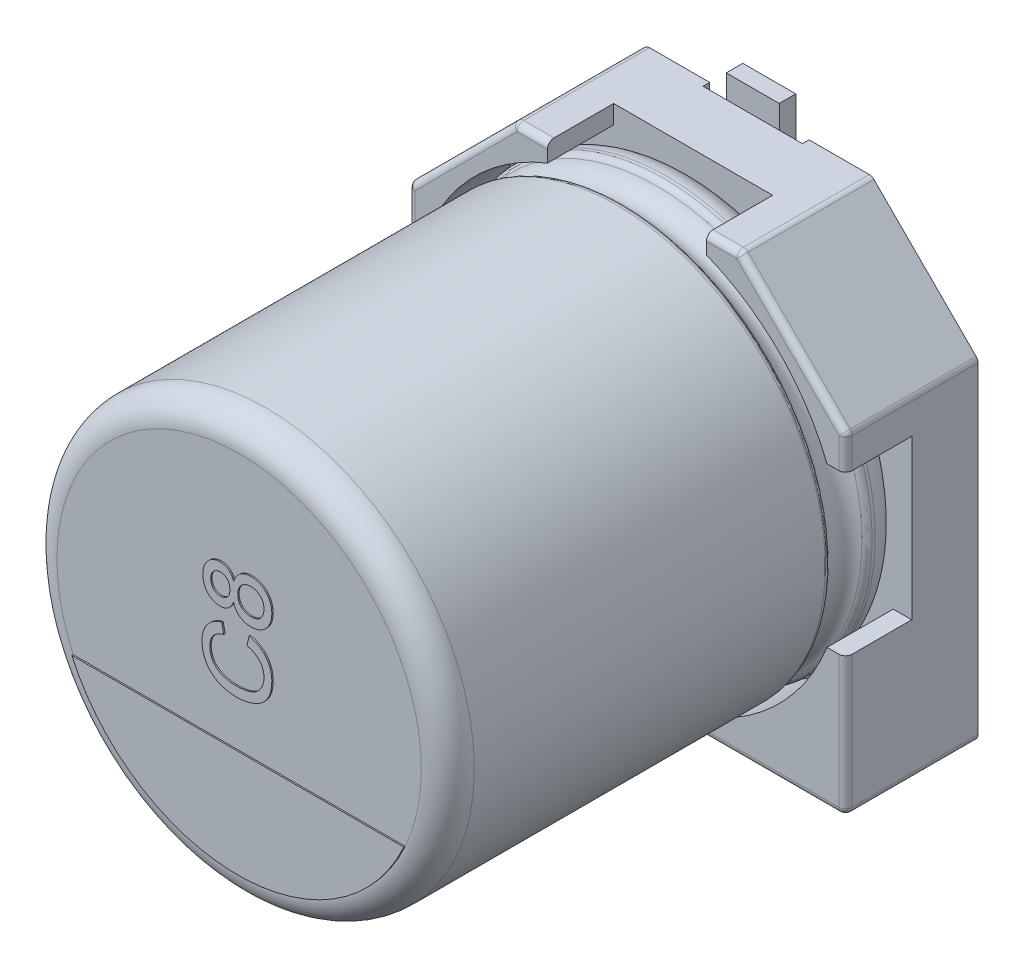
from build123d import *

# Parameters (mm, degrees)
BOSS_EXTRUDE1_DEPTH = 1
BOSS_EXTRUDE2_DEPTH = 1
SKETCH7_R           = 0.35
BOSS_EXTRUDE3_DEPTH = 0.15
SKETCH9_W           = 1.5
SKETCH9_H           = 2.35
CUT_EXTRUDE1_DEPTH  = 0.1
FILLET1_R           = 0.1
FILLET2_R           = 0.1
BOSS_EXTRUDE4_DEPTH = 0.02
TEXT_2_DEPTH        = 0.02
SKETCH19_W          = 0.8
SKETCH19_H          = 2.6
BOSS_EXTRUDE6_DEPTH = 0.25


with BuildPart() as part:
    # Sketch2 → Boss-Extrude1 (new body)
    with BuildSketch(Plane.XY):
        Polygon((-3.3, 1.7), (-1.7, 3.3), (1.7, 3.3), (3.3, 1.7), (3.3, -3.3), (-3.3, -3.3), align=None)
    extrude(amount=BOSS_EXTRUDE1_DEPTH)

    # Sketch4 → Boss-Extrude2 (add)
    with BuildSketch(Plane.XY.offset(1)):
        with BuildLine():
            Line((-3.3, 1.7), (-1.7, 3.3))
            Line((-1.7, 3.3), (-1.2, 3.3))
            Line((-1.2, 3.3), (-1.2, 3.020347662))
            ThreePointArc((-1.2, 3.020347662), (-2.298097039, 2.298097039), (-3.020347662, 1.2))
            Line((-3.020347662, 1.2), (-3.3, 1.2))
            Line((-3.3, 1.2), (-3.3, 1.7))
        make_face()
        with BuildLine():
            Line((1.7, 3.3), (3.3, 1.7))
            Line((3.3, 1.7), (3.3, 1.2))
            Line((3.3, 1.2), (3.020347662, 1.2))
            ThreePointArc((3.020347662, 1.2), (2.298097039, 2.298097039), (1.2, 3.020347662))
            Line((1.2, 3.020347662), (1.2, 3.3))
            Line((1.2, 3.3), (1.7, 3.3))
        make_face()
        with BuildLine():
            Line((3.3, -1.2), (3.3, -3.3))
            Line((3.3, -3.3), (1.2, -3.3))
            Line((1.2, -3.3), (1.2, -3.020347662))
            ThreePointArc((1.2, -3.020347662), (2.298097039, -2.298097039), (3.020347662, -1.2))
            Line((3.020347662, -1.2), (3.3, -1.2))
        make_face()
        with BuildLine():
            Line((-3.3, -1.2), (-3.3, -3.3))
            Line((-3.3, -3.3), (-1.2, -3.3))
            Line((-1.2, -3.3), (-1.2, -3.020347662))
            ThreePointArc((-1.2, -3.020347662), (-2.298097039, -2.298097039), (-3.020347662, -1.2))
            Line((-3.020347662, -1.2), (-3.3, -1.2))
        make_face()
    extrude(amount=BOSS_EXTRUDE2_DEPTH)

    # Sketch7 → Boss-Extrude3 (add)
    with BuildSketch(Plane(origin=(0, 0, 0), x_dir=(1, 0, 0), z_dir=(0, 0, -1))):
        with Locations((-2.232271432, 1.911844843)):
            Circle(SKETCH7_R)
        with Locations((2.232271432, 1.911844843)):
            Circle(SKETCH7_R)
        with Locations((-2.232271432, -1.911844843)):
            Circle(SKETCH7_R)
        with Locations((2.232271432, -1.911844843)):
            Circle(SKETCH7_R)
    extrude(amount=BOSS_EXTRUDE3_DEPTH)

    # Sketch9 → Cut-Extrude1 (cut)
    with BuildSketch(Plane(origin=(0, 0, 0), x_dir=(1, 0, 0), z_dir=(0, 0, -1))):
        with Locations((0, 2.125)):
            Rectangle(SKETCH9_W, SKETCH9_H)
        with Locations((0, -2.125)):
            Rectangle(SKETCH9_W, SKETCH9_H)
    extrude(amount=-CUT_EXTRUDE1_DEPTH, mode=Mode.SUBTRACT)

    # Fillet1
    fillet1_edges = [part.edges().sort_by_distance(p)[0] for p in [
        (3.3, -3.3, 1),
        (-3.3, -3.3, 1),
        (-3.3, 1.7, 1),
        (-1.7, 3.3, 1),
        (1.7, 3.3, 1),
        (3.3, 1.7, 1),
    ]]
    fillet(fillet1_edges, radius=FILLET1_R)

    # Sketch10 → Revolve1 (revolve)
    with BuildSketch(Plane(origin=(0, 0, 0), x_dir=(0, 0, -1), z_dir=(1, 0, 0))):
        with BuildLine():
            Line((-7.853626625, 0), (-1, 0))
            Line((-1, 0), (-1, 2.75))
            ThreePointArc((-1, 2.75), (-1.117157288, 3.032842712), (-1.4, 3.15))
            Line((-1.4, 3.15), (-1.449422929, 3.15))
            ThreePointArc((-1.449422929, 3.15), (-1.504479696, 3.133479053), (-1.541344666, 3.089375046))
            ThreePointArc((-1.541344666, 3.089375046), (-1.801990181, 2.917472047), (-2.062635697, 3.089375046))
            ThreePointArc((-2.062635697, 3.089375046), (-2.099500666, 3.133479053), (-2.154557434, 3.15))
            Line((-2.154557434, 3.15), (-7.453626625, 3.15))
            ThreePointArc((-7.453626625, 3.15), (-7.736469337, 3.032842712), (-7.853626625, 2.75))
            Line((-7.853626625, 2.75), (-7.853626625, 0))
        make_face()
    revolve(axis=Axis((0, 0, -18.9630778), (0, 0, 1)))

    # Fillet2
    fillet2_edges = [part.edges().sort_by_distance(p)[0] for p in [
        (2.2, -3.3, 2),
        (3.270710678, -3.270710678, 2),
        (3.3, 1.429289322, 2),
        (3.292387953, 1.696846987, 2),
        (1.429289322, 3.3, 2),
        (1.696846987, 3.292387953, 2),
        (-1.429289322, 3.3, 2),
        (-1.696846987, 3.292387953, 2),
        (-2.5, 2.5, 2),
        (-3.292387953, 1.696846987, 2),
        (-3.3, -2.2, 2),
        (-3.270710678, -3.270710678, 2),
        (3.3, -2.2, 2),
        (2.5, 2.5, 2),
        (-3.3, 1.429289322, 2),
        (-2.2, -3.3, 2),
    ]]
    fillet(fillet2_edges, radius=FILLET2_R)

    # Sketch13 → Boss-Extrude4 (add)
    with BuildSketch(Plane.XY.offset(7.853626625)):
        with BuildLine():
            Line((-2.506238836, -1.131930607), (2.506238836, -1.131930607))
            ThreePointArc((2.506238836, -1.131930607), (0, -2.75), (-2.506238836, -1.131930607))
        make_face()
    extrude(amount=BOSS_EXTRUDE4_DEPTH)

    # Sketch15 → Text 2 (add)
    with BuildSketch(Plane.XY.offset(7.853626625)):
        with BuildLine():
            Line((0.137389622, 0.316593633), (0.171139963, 0.461473149))
            add(Edge.make_bspline(
                [(0.171139963, 0.461473149), (0.184719205, 0.457843617), (0.211281888, 0.450743802), (0.249294555, 0.436704736), (0.284973396, 0.420954535), (0.318198658, 0.403080099), (0.348825876, 0.383025378), (0.37700883, 0.360877976), (0.402792333, 0.336641169), (0.425858287, 0.31012897), (0.446489175, 0.282031663), (0.464171898, 0.252152583), (0.479591278, 0.221021834), (0.491950748, 0.188130242), (0.501325327, 0.153719305), (0.508136304, 0.117874786), (0.512336792, 0.080509598), (0.512889354, 0.055039538), (0.513170865, 0.042063415)],
                knots=[0, 0, 0, 0, 1.145367768, 2.240481511, 3.299486216, 4.322926322, 5.312543435, 6.280301985, 7.2416403, 8.192823262, 9.141388579, 10.079393599, 11.019812878, 11.970222822, 12.938950422, 13.923894909, 14.942295558, 16, 16, 16, 16], degree=3))
            add(Edge.make_bspline(
                [(0.513170865, 0.042063415), (0.512974968, 0.028750287), (0.512591712, 0.002704216), (0.509548347, -0.035461334), (0.50408886, -0.071710574), (0.497105361, -0.106172698), (0.487517876, -0.138603304), (0.476080502, -0.169237106), (0.462232577, -0.197809744), (0.446522059, -0.224623591), (0.428664346, -0.249552903), (0.409152567, -0.273167676), (0.387446592, -0.294893809), (0.364059715, -0.315274756), (0.338683214, -0.333866555), (0.311661899, -0.351353217), (0.282519639, -0.366881226), (0.251796737, -0.381026037), (0.219790643, -0.393441241), (0.187133568, -0.404424353), (0.153760439, -0.413403647), (0.119952084, -0.421134241), (0.085424029, -0.426750142), (0.050435341, -0.431208994), (0.014771509, -0.433660561), (-0.009201459, -0.433983161), (-0.021278143, -0.434145675)],
                knots=[0, 0, 0, 0, 1.180680974, 2.309907975, 3.39230657, 4.430402719, 5.425739985, 6.38846843, 7.327253855, 8.238163682, 9.141319901, 10.044148192, 10.951882972, 11.861898394, 12.79276478, 13.739539846, 14.714057202, 15.718574761, 16.737652364, 17.7573291, 18.772768038, 19.801551793, 20.831755737, 21.873891013, 22.928945814, 24, 24, 24, 24], degree=3))
            add(Edge.make_bspline(
                [(-0.021278143, -0.434145675), (-0.034315397, -0.4339132), (-0.060073717, -0.433453889), (-0.098081116, -0.430862244), (-0.134761949, -0.426098769), (-0.17014477, -0.419495443), (-0.204305873, -0.411082573), (-0.23725329, -0.400840529), (-0.268852986, -0.388622281), (-0.299113504, -0.374745627), (-0.327665253, -0.358785546), (-0.354762577, -0.3416054), (-0.379878011, -0.322520006), (-0.403474105, -0.302187934), (-0.425149261, -0.280085417), (-0.444954877, -0.256284136), (-0.463070995, -0.230988325), (-0.479329594, -0.204201975), (-0.493595656, -0.176275134), (-0.506302564, -0.147622628), (-0.516717602, -0.118130488), (-0.525377287, -0.088032537), (-0.532271201, -0.057263976), (-0.536881183, -0.025752912), (-0.539885404, 0.006471539), (-0.540292549, 0.02819978), (-0.540498339, 0.039182288)],
                knots=[0, 0, 0, 0, 1.185610122, 2.34246615, 3.46204209, 4.547238403, 5.613845268, 6.659506797, 7.682407252, 8.692734231, 9.683951048, 10.654680354, 11.607833779, 12.549673105, 13.484816388, 14.419272854, 15.362680812, 16.31159957, 17.265732262, 18.21261905, 19.159670199, 20.10733745, 21.059306249, 22.024427552, 23.00144979, 24, 24, 24, 24], degree=3))
            add(Edge.make_bspline(
                [(-0.540498339, 0.039182288), (-0.54027585, 0.051472155), (-0.539838527, 0.075629106), (-0.53596558, 0.111030265), (-0.53016218, 0.145076857), (-0.521400985, 0.17750367), (-0.510653256, 0.208616176), (-0.496791219, 0.237924274), (-0.481084534, 0.266024209), (-0.462639265, 0.292395393), (-0.442059798, 0.317116672), (-0.419396701, 0.339965227), (-0.394799964, 0.360899322), (-0.368077184, 0.379659831), (-0.339408707, 0.396504218), (-0.308850674, 0.411613497), (-0.276208278, 0.424627676), (-0.253468798, 0.431587541), (-0.241890133, 0.435131419)],
                knots=[0, 0, 0, 0, 1.098215313, 2.158650937, 3.179873416, 4.182349117, 5.157851008, 6.118027029, 7.076341197, 8.032298369, 8.990121974, 9.948357669, 10.905435138, 11.873450097, 12.863034414, 13.874936208, 14.917943528, 16, 16, 16, 16], degree=3))
            Line((-0.241890133, 0.435131419), (-0.210815123, 0.290251903))
            add(Edge.make_bspline(
                [(-0.210815123, 0.290251903), (-0.21970095, 0.287406696), (-0.237093262, 0.281837744), (-0.261880399, 0.271949526), (-0.284890959, 0.26127058), (-0.305968529, 0.249546525), (-0.325118157, 0.236751953), (-0.342572578, 0.223181488), (-0.358006003, 0.208509995), (-0.371774287, 0.193035906), (-0.383503548, 0.176359634), (-0.393897604, 0.158872143), (-0.402497099, 0.140204709), (-0.409770496, 0.120625878), (-0.415306335, 0.099952647), (-0.419201016, 0.078269202), (-0.421455067, 0.05555649), (-0.421789822, 0.040079052), (-0.421960554, 0.032185266)],
                knots=[0, 0, 0, 0, 1.235697765, 2.418642872, 3.532555292, 4.594392283, 5.610119701, 6.580908344, 7.519430642, 8.427315627, 9.319973334, 10.216139639, 11.118687699, 12.038725643, 12.980015607, 13.949697744, 14.954307006, 16, 16, 16, 16], degree=3))
            add(Edge.make_bspline(
                [(-0.421960554, 0.032185266), (-0.42182894, 0.023122531), (-0.421570094, 0.005298806), (-0.418741414, -0.020887312), (-0.414566199, -0.046031584), (-0.408336958, -0.06996279), (-0.400471327, -0.092727501), (-0.391074044, -0.1144289), (-0.379637086, -0.134923416), (-0.366527285, -0.154190234), (-0.351810113, -0.172119905), (-0.335998775, -0.188775555), (-0.319056253, -0.204115277), (-0.300881808, -0.217955028), (-0.281409051, -0.230297385), (-0.260823414, -0.241466755), (-0.238987177, -0.251110914), (-0.208358467, -0.262011565), (-0.168833348, -0.2727293), (-0.120495718, -0.282252213), (-0.071437696, -0.288256875), (-0.038444502, -0.28892902), (-0.021895528, -0.289266159)],
                knots=[0, 0, 0, 0, 0.935100075, 1.839065892, 2.715632844, 3.564034634, 4.388093667, 5.199800233, 6.00171917, 6.806945003, 7.602082793, 8.393428172, 9.17553264, 9.958694158, 10.748327009, 11.553054559, 12.374096334, 13.209545573, 14.906836637, 16.595465087, 18.292327764, 20, 20, 20, 20], degree=3))
            add(Edge.make_bspline(
                [(-0.021895528, -0.289266159), (-0.001088295, -0.28888169), (0.039347759, -0.288134525), (0.097860474, -0.280941105), (0.152411861, -0.269796756), (0.194923463, -0.256480088), (0.226325575, -0.243084208), (0.248317261, -0.232252213), (0.268667217, -0.219887416), (0.287491124, -0.206297945), (0.304734045, -0.191308606), (0.320487583, -0.175128268), (0.334903322, -0.157753307), (0.347306436, -0.138977849), (0.35831932, -0.119524584), (0.368112186, -0.099638997), (0.376394559, -0.079308568), (0.382828475, -0.058451271), (0.388388272, -0.03736), (0.392020193, -0.015802455), (0.394069935, 0.006215216), (0.39444386, 0.020999538), (0.39463308, 0.02848096)],
                knots=[0, 0, 0, 0, 2.106854985, 4.094388766, 5.961441423, 7.741458329, 8.594569961, 9.418076185, 10.222480919, 11.003619353, 11.767127393, 12.533696482, 13.289066307, 14.050325982, 14.809648647, 15.552384038, 16.294338903, 17.030544626, 17.761979889, 18.502240791, 19.242077596, 20, 20, 20, 20], degree=3))
            add(Edge.make_bspline(
                [(0.39463308, 0.02848096), (0.39444584, 0.037409013), (0.394075974, 0.055045074), (0.390838523, 0.080901779), (0.386067714, 0.105827286), (0.378705874, 0.129519626), (0.369692165, 0.152297488), (0.358576684, 0.173974247), (0.345208005, 0.194481731), (0.330029126, 0.214061155), (0.312758155, 0.232351457), (0.293534236, 0.249113535), (0.27226973, 0.264151013), (0.249305901, 0.278094539), (0.223956735, 0.289809664), (0.196977778, 0.300660635), (0.167925608, 0.309702449), (0.147714502, 0.314263574), (0.137389622, 0.316593633)],
                knots=[0, 0, 0, 0, 1.013374089, 2.001772144, 2.95501459, 3.891367103, 4.814208647, 5.733921849, 6.652182523, 7.590185968, 8.54346024, 9.504121027, 10.481158517, 11.497760682, 12.549996529, 13.647863555, 14.798406869, 16, 16, 16, 16], degree=3))
        make_face()
        with BuildLine():
            add(Edge.make_bspline(
                [(-0.06346607, 0.788275238), (-0.068354899, 0.775778413), (-0.077728405, 0.751817855), (-0.096487429, 0.719501239), (-0.118067216, 0.69215039), (-0.142988147, 0.670101139), (-0.17073504, 0.653295601), (-0.200954123, 0.64119495), (-0.233813748, 0.634107386), (-0.256535333, 0.63317458), (-0.268231863, 0.632694394)],
                knots=[0, 0, 0, 0, 1.16287356, 2.229614231, 3.228817875, 4.173350329, 5.100165549, 6.029633206, 6.985702163, 8, 8, 8, 8], degree=3))
            add(Edge.make_bspline(
                [(-0.268231863, 0.632694394), (-0.277232165, 0.632919534), (-0.29490004, 0.633361489), (-0.320818877, 0.637206949), (-0.345615231, 0.643285934), (-0.369240102, 0.652152992), (-0.392048008, 0.662898893), (-0.413437716, 0.676750247), (-0.434030491, 0.69257138), (-0.453013793, 0.711122344), (-0.470402473, 0.731560623), (-0.485876208, 0.753699695), (-0.498530082, 0.777707507), (-0.509109754, 0.803184172), (-0.517392528, 0.830255553), (-0.523033555, 0.859017039), (-0.526621668, 0.889367231), (-0.527088541, 0.910163903), (-0.527327474, 0.920807067)],
                knots=[0, 0, 0, 0, 0.994120188, 1.951489002, 2.889176796, 3.810168517, 4.735797202, 5.669554404, 6.620327554, 7.601413351, 8.596342518, 9.582569514, 10.579662357, 11.589070759, 12.627413041, 13.702304436, 14.824102725, 16, 16, 16, 16], degree=3))
            add(Edge.make_bspline(
                [(-0.527327474, 0.920807067), (-0.527086115, 0.931518051), (-0.526615976, 0.952381837), (-0.523076073, 0.982893274), (-0.517142977, 1.011836263), (-0.508725404, 1.039193757), (-0.497963042, 1.065008915), (-0.484734644, 1.089111998), (-0.469258577, 1.111751533), (-0.451349578, 1.132347377), (-0.431908305, 1.151091382), (-0.411072648, 1.167316131), (-0.389310753, 1.181319257), (-0.366468595, 1.192655647), (-0.342477715, 1.201324109), (-0.317627507, 1.207752334), (-0.291602408, 1.211528386), (-0.27393779, 1.211981588), (-0.264939147, 1.212212457)],
                knots=[0, 0, 0, 0, 1.17123639, 2.281436327, 3.354066579, 4.398218719, 5.40700272, 6.407523026, 7.400164541, 8.400262835, 9.387217769, 10.349220476, 11.2836808, 12.213067748, 13.131580738, 14.068687581, 15.016158091, 16, 16, 16, 16], degree=3))
            add(Edge.make_bspline(
                [(-0.264939147, 1.212212457), (-0.253645841, 1.211835972), (-0.231501792, 1.211097755), (-0.199579354, 1.203577504), (-0.169784312, 1.191851139), (-0.142655025, 1.174922747), (-0.117991462, 1.153381666), (-0.096234769, 1.126961497), (-0.077820532, 1.095359139), (-0.068384192, 1.072064993), (-0.06346607, 1.059924329)],
                knots=[0, 0, 0, 0, 0.998585552, 1.958038425, 2.887636572, 3.823348935, 4.774921793, 5.776035998, 6.840893412, 8, 8, 8, 8], degree=3))
            add(Edge.make_bspline(
                [(-0.06346607, 1.059924329), (-0.060862641, 1.067593823), (-0.055761048, 1.082622703), (-0.04584198, 1.103869054), (-0.035146871, 1.123871857), (-0.023569407, 1.142743903), (-0.010248607, 1.159788599), (0.00402795, 1.175574532), (0.019461358, 1.190035602), (0.036183215, 1.202973277), (0.053841314, 1.214526891), (0.072483356, 1.224406987), (0.091886088, 1.232863914), (0.112087026, 1.239910378), (0.133157783, 1.245270444), (0.15505702, 1.248893063), (0.177743724, 1.251229912), (0.193154177, 1.251558289), (0.200980204, 1.251725052)],
                knots=[0, 0, 0, 0, 1.104224237, 2.163800432, 3.193825792, 4.198757877, 5.179651902, 6.140335883, 7.100472673, 8.060837497, 9.021293519, 9.975895278, 10.935667101, 11.906463585, 12.891589942, 13.897828549, 14.932435592, 16, 16, 16, 16], degree=3))
            add(Edge.make_bspline(
                [(0.200980204, 1.251725052), (0.211766209, 1.251463047), (0.233015459, 1.250946876), (0.26420908, 1.246419944), (0.294166278, 1.239551014), (0.322741766, 1.229626162), (0.349926401, 1.216683295), (0.375922546, 1.201069684), (0.400458109, 1.182410561), (0.423424312, 1.161218992), (0.444607119, 1.137981639), (0.463042568, 1.112510529), (0.478495248, 1.085123723), (0.491395014, 1.05609501), (0.50090607, 1.025082357), (0.508283383, 0.992512157), (0.512303421, 0.958019283), (0.512877843, 0.934467551), (0.513170865, 0.922453425)],
                knots=[0, 0, 0, 0, 1.017684271, 2.004915574, 2.969350057, 3.91550174, 4.854021697, 5.806886265, 6.773058391, 7.758397691, 8.753308551, 9.736453685, 10.719577492, 11.717014045, 12.728747378, 13.776699948, 14.865858151, 16, 16, 16, 16], degree=3))
            add(Edge.make_bspline(
                [(0.513170865, 0.922453425), (0.512880184, 0.910438476), (0.51231035, 0.886885128), (0.508257359, 0.852403856), (0.500993774, 0.819771647), (0.49106014, 0.788914563), (0.478602189, 0.759665214), (0.462789127, 0.732455551), (0.444350128, 0.706910714), (0.423269613, 0.683434691), (0.40009517, 0.662276739), (0.375232143, 0.643859299), (0.349063166, 0.628160314), (0.321440718, 0.61524039), (0.292364548, 0.605392462), (0.261943817, 0.598481069), (0.230201772, 0.593942176), (0.208542071, 0.59343883), (0.197481693, 0.593181799)],
                knots=[0, 0, 0, 0, 1.127066097, 2.209429196, 3.250843736, 4.258219581, 5.246860502, 6.227045772, 7.204057202, 8.19754525, 9.181483529, 10.142920909, 11.095356922, 12.039670968, 12.998174893, 13.969127444, 14.962948905, 16, 16, 16, 16], degree=3))
            add(Edge.make_bspline(
                [(0.197481693, 0.593181799), (0.189246409, 0.593360436), (0.173087356, 0.593710953), (0.149386601, 0.595852625), (0.126796614, 0.600119472), (0.105187415, 0.605620045), (0.084493636, 0.612587536), (0.064863806, 0.621266937), (0.046256659, 0.63158768), (0.028790272, 0.643542447), (0.012456006, 0.656890854), (-0.002360853, 0.671834087), (-0.01598593, 0.687936669), (-0.028435302, 0.705271178), (-0.039376701, 0.724091201), (-0.048734162, 0.744345342), (-0.057112711, 0.765740846), (-0.061327074, 0.780688546), (-0.06346607, 0.788275238)],
                knots=[0, 0, 0, 0, 1.117192714, 2.192125398, 3.223277125, 4.232061974, 5.214850236, 6.181337876, 7.139322725, 8.096810377, 9.04872078, 9.996164021, 10.946891304, 11.907403346, 12.887280159, 13.894604929, 14.93140868, 16, 16, 16, 16], degree=3))
        make_face()
        with BuildLine():
            add(Edge.make_bspline(
                [(-0.267614479, 0.764403045), (-0.257129573, 0.764793965), (-0.236868083, 0.765549395), (-0.208087697, 0.773764434), (-0.182236441, 0.786611088), (-0.163484759, 0.801669379), (-0.150719359, 0.816111262), (-0.142164759, 0.828152128), (-0.135012669, 0.841384049), (-0.128993841, 0.855621727), (-0.124418959, 0.871011153), (-0.121517723, 0.887592973), (-0.119286059, 0.905244362), (-0.119117208, 0.917437967), (-0.119030657, 0.923688194)],
                knots=[0, 0, 0, 0, 1.528611259, 2.9539551, 4.33488699, 5.725248612, 6.435430486, 7.147520411, 7.878829355, 8.629199951, 9.403175758, 10.219188982, 11.087187622, 12, 12, 12, 12], degree=3))
            add(Edge.make_bspline(
                [(-0.119030657, 0.923688194), (-0.119118527, 0.929800932), (-0.119289868, 0.941720435), (-0.121500048, 0.958967668), (-0.124496051, 0.97524751), (-0.1288828, 0.990430674), (-0.135118016, 1.004332488), (-0.14191772, 1.017437349), (-0.150526036, 1.029212783), (-0.163313755, 1.043332426), (-0.181426583, 1.05826536), (-0.205975026, 1.071285277), (-0.232964043, 1.07925345), (-0.251781791, 1.080079704), (-0.261440636, 1.080503806)],
                knots=[0, 0, 0, 0, 0.922426077, 1.79868034, 2.621444266, 3.421127716, 4.177365866, 4.918918382, 5.646226505, 6.372279565, 7.792748194, 9.164334355, 10.544498862, 12, 12, 12, 12], degree=3))
            add(Edge.make_bspline(
                [(-0.261440636, 1.080503806), (-0.271437729, 1.079995245), (-0.290999452, 1.079000123), (-0.319104756, 1.071009853), (-0.344515741, 1.057412425), (-0.363325638, 1.04225191), (-0.376567635, 1.027766332), (-0.385082022, 1.015570705), (-0.392715367, 1.002621331), (-0.398298846, 0.988367065), (-0.4031971, 0.973370537), (-0.406317846, 0.95726307), (-0.408535579, 0.940213693), (-0.408703203, 0.928498082), (-0.408789689, 0.922453425)],
                knots=[0, 0, 0, 0, 1.480375879, 2.896712224, 4.288636353, 5.727462819, 6.454578368, 7.191019914, 7.928864207, 8.676661479, 9.454949272, 10.264623217, 11.104634354, 12, 12, 12, 12], degree=3))
            add(Edge.make_bspline(
                [(-0.408789689, 0.922453425), (-0.408707781, 0.91640758), (-0.408548105, 0.904621499), (-0.406239515, 0.88746815), (-0.403494721, 0.871162528), (-0.398497735, 0.856125193), (-0.392892961, 0.841928879), (-0.385509663, 0.828926443), (-0.377188483, 0.816736824), (-0.364322549, 0.8023776), (-0.34623511, 0.787333564), (-0.321930657, 0.774082082), (-0.295432267, 0.765891808), (-0.277001926, 0.764905446), (-0.267614479, 0.764403045)],
                knots=[0, 0, 0, 0, 0.91490328, 1.783559258, 2.619081745, 3.414352434, 4.178467273, 4.927311119, 5.673844605, 6.409891731, 7.841381988, 9.212979491, 10.580438247, 12, 12, 12, 12], degree=3))
        make_face(mode=Mode.SUBTRACT)
        with BuildLine():
            add(Edge.make_bspline(
                [(0.195012156, 0.72489045), (0.203533443, 0.725108341), (0.220461909, 0.725541204), (0.245646107, 0.729640267), (0.270289152, 0.73627868), (0.29446295, 0.745124237), (0.317223577, 0.757329682), (0.337556487, 0.773625336), (0.354705064, 0.793979221), (0.368908515, 0.817425102), (0.380259094, 0.842848666), (0.388514475, 0.869302158), (0.393687613, 0.896253256), (0.394317888, 0.91440498), (0.39463308, 0.923482399)],
                knots=[0, 0, 0, 0, 0.965767917, 1.918603253, 2.884747077, 3.857165743, 4.83191542, 5.800217878, 6.793357779, 7.834047487, 8.899591186, 9.942836448, 10.971241714, 12, 12, 12, 12], degree=3))
            add(Edge.make_bspline(
                [(0.39463308, 0.923482399), (0.394506238, 0.930968938), (0.39425982, 0.945513147), (0.391444872, 0.966714358), (0.387171918, 0.98668954), (0.38131905, 1.005535514), (0.37329041, 1.022956076), (0.363961235, 1.039339441), (0.35239897, 1.054223471), (0.339512355, 1.067931926), (0.325396783, 1.08033652), (0.309987757, 1.090778971), (0.293890018, 1.099964196), (0.276740007, 1.107450654), (0.258518154, 1.112867769), (0.23954893, 1.117046915), (0.219637866, 1.119568284), (0.20606374, 1.119864864), (0.199128051, 1.120016401)],
                knots=[0, 0, 0, 0, 1.149503616, 2.233157837, 3.279104951, 4.285657945, 5.257288299, 6.220710859, 7.175564347, 8.14479123, 9.108444329, 10.055589725, 10.999387165, 11.952843816, 12.922929765, 13.915146356, 14.934745671, 16, 16, 16, 16], degree=3))
            add(Edge.make_bspline(
                [(0.199128051, 1.120016401), (0.192056214, 1.119860051), (0.178210684, 1.119553943), (0.15786274, 1.117096455), (0.138559314, 1.112683661), (0.120012744, 1.107004154), (0.102531334, 1.099323969), (0.085868825, 1.090016246), (0.070322849, 1.078842424), (0.05566719, 1.066365135), (0.042426027, 1.052332747), (0.030949228, 1.036904153), (0.021138856, 1.020308848), (0.013340834, 1.002442535), (0.007158914, 0.983415234), (0.002647348, 0.963236795), (-0.000105556, 0.941805917), (-0.000361274, 0.927126612), (-0.000492872, 0.919572299)],
                knots=[0, 0, 0, 0, 1.065650327, 2.086373591, 3.082132111, 4.046704089, 5.005106566, 5.954038819, 6.917890284, 7.885615098, 8.851017768, 9.818687358, 10.777925871, 11.749948522, 12.750365274, 13.788736846, 14.862032431, 16, 16, 16, 16], degree=3))
            add(Edge.make_bspline(
                [(-0.000492872, 0.919572299), (-0.000359965, 0.91222313), (-9.9427e-05, 0.897816472), (0.002669058, 0.876886462), (0.006928426, 0.857076343), (0.013134854, 0.838541171), (0.020971302, 0.821150515), (0.030472426, 0.804936311), (0.041878437, 0.790011496), (0.055055679, 0.776549548), (0.069403746, 0.764430166), (0.084799219, 0.753866233), (0.10098144, 0.744720552), (0.11825962, 0.73762164), (0.136157909, 0.731680992), (0.155039621, 0.72795646), (0.174700988, 0.725312001), (0.188142811, 0.725033021), (0.195012156, 0.72489045)],
                knots=[0, 0, 0, 0, 1.134968506, 2.224891707, 3.256179866, 4.261763128, 5.239014399, 6.198865146, 7.159242496, 8.133730563, 9.104116964, 10.05674163, 11.0152453, 11.970049417, 12.938813484, 13.924193867, 14.939174528, 16, 16, 16, 16], degree=3))
        make_face(mode=Mode.SUBTRACT)
    extrude(amount=TEXT_2_DEPTH)

    # Sketch19 → Boss-Extrude6 (add)
    with BuildSketch(Plane(origin=(0, 0, 0.1), x_dir=(1, 0, 0), z_dir=(0, 0, -1))):
        with Locations((0, 2.35)):
            Rectangle(SKETCH19_W, SKETCH19_H)
        with Locations((0, -2.35)):
            Rectangle(SKETCH19_W, SKETCH19_H)
    extrude(amount=BOSS_EXTRUDE6_DEPTH)


solid = part.part
